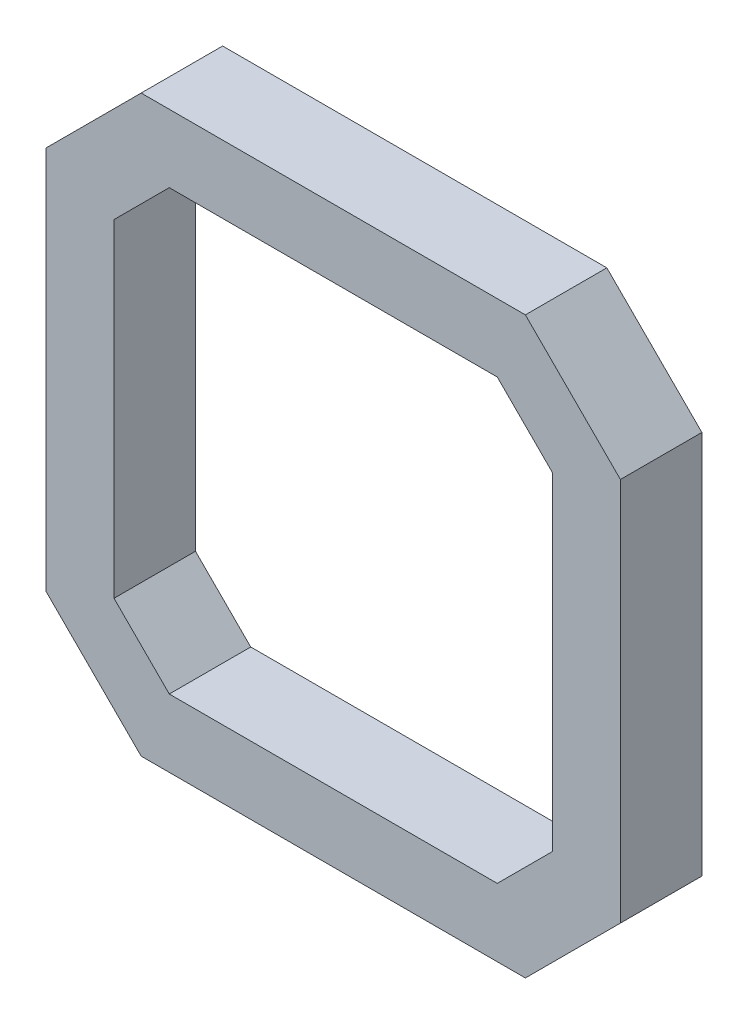
from build123d import *

# Parameters (mm, degrees)
ESTRUSIONE_ESTRUSIONE1_DEPTH = 6


with BuildPart() as part:
    # Schizzo1 → Estrusione-Estrusione1 (new body)
    with BuildSketch(Plane.XY):
        Polygon((-21.15, 14.15), (-14.15, 21.15), (14.15, 21.15), (21.15, 14.15), (21.15, -14.15), (14.15, -21.15), (-14.15, -21.15), (-21.15, -14.15), align=None)
        Polygon((-12.078932188, 16.15), (12.078932188, 16.15), (16.15, 12.078932188), (16.15, -12.078932188), (12.078932188, -16.15), (-12.078932188, -16.15), (-16.15, -12.078932188), (-16.15, 12.078932188), align=None, mode=Mode.SUBTRACT)
    extrude(amount=ESTRUSIONE_ESTRUSIONE1_DEPTH)


solid = part.part
